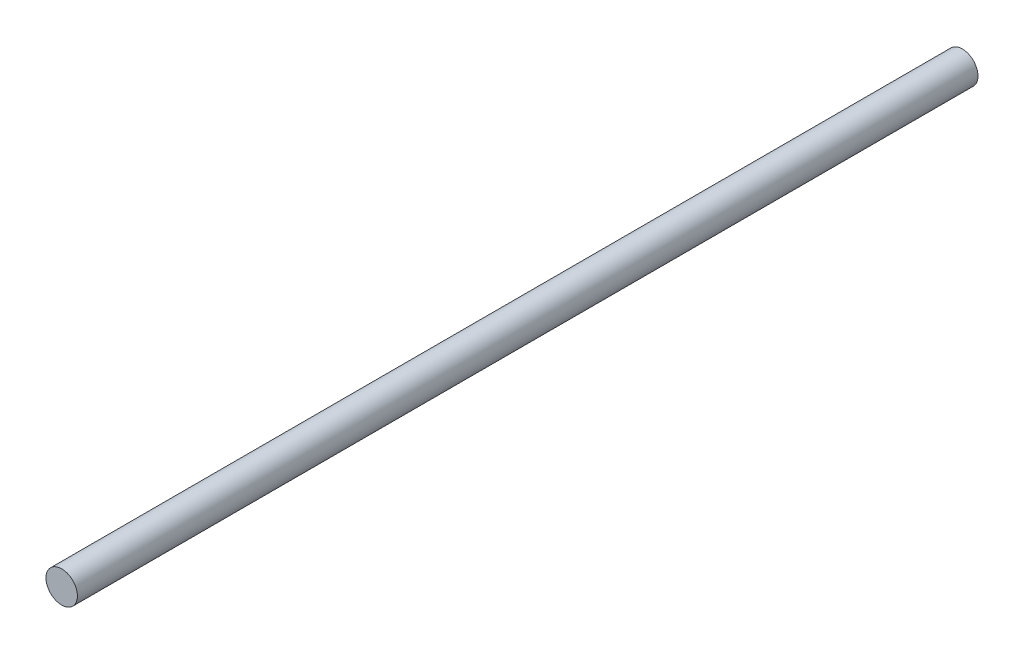
from build123d import *

# Parameters (mm, degrees)
SKETCH1_R           = 3.9878
BOSS_EXTRUDE1_DEPTH = 228.6


with BuildPart() as part:
    # Sketch1 → Boss-Extrude1 (new body)
    with BuildSketch(Plane.XY):
        Circle(SKETCH1_R)
    extrude(amount=BOSS_EXTRUDE1_DEPTH)


solid = part.part
